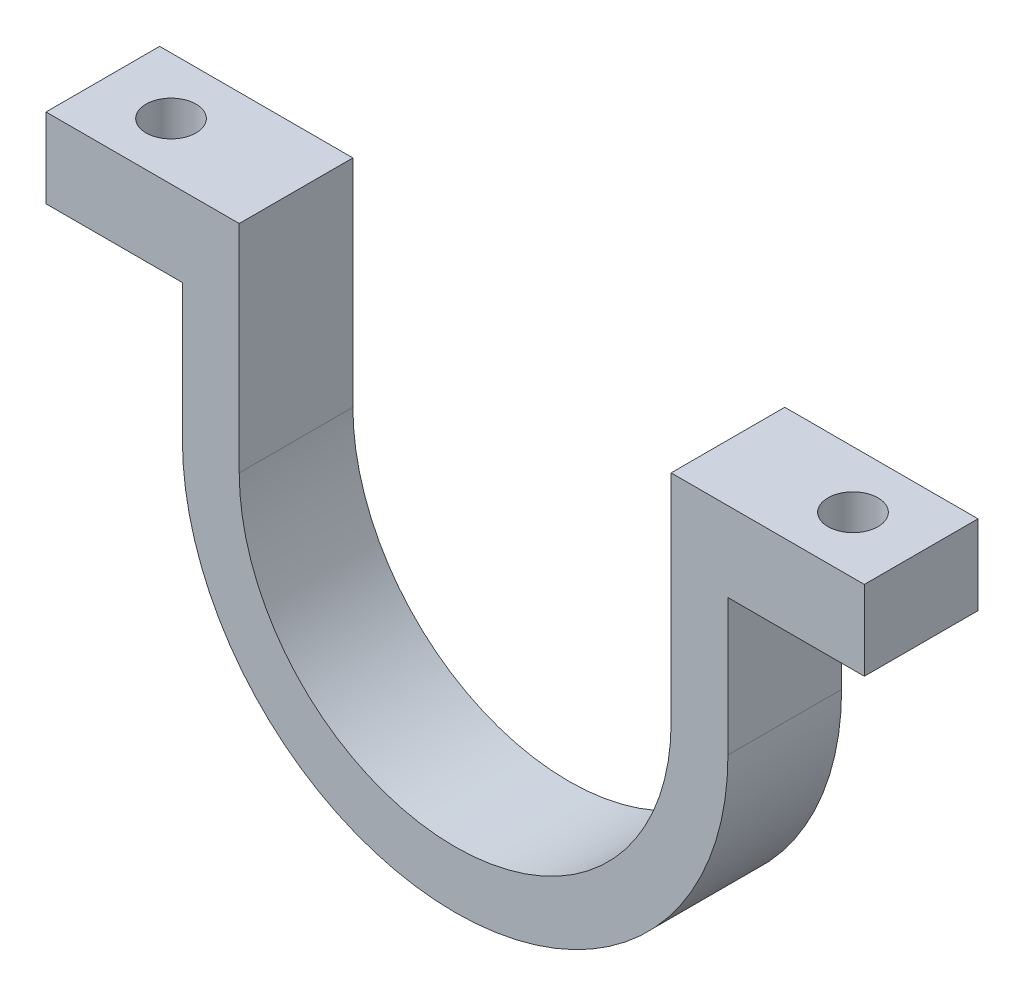
from build123d import *

# Parameters (mm, degrees)
RESSALTO_EXTRUS_O1_DEPTH = 10
ESBO_O2_R                = 2.2
CORTE_EXTRUS_O1_DEPTH    = 10


with BuildPart() as part:
    # Esboço1 → Ressalto-extrusão1 (new body)
    with BuildSketch(Plane.XY):
        with BuildLine():
            Line((-36, 19), (-19, 19))
            Line((-19, 19), (-19, 0))
            ThreePointArc((-19, 0), (0, -19), (19, 0))
            Line((19, 0), (19, 19))
            Line((19, 19), (36, 19))
            Line((36, 19), (36, 12))
            Line((36, 12), (24, 12))
            Line((24, 12), (24, 0))
            ThreePointArc((24, 0), (0, -24), (-24, 0))
            Line((-24, 0), (-24, 12))
            Line((-24, 12), (-36, 12))
            Line((-36, 12), (-36, 19))
        make_face()
    extrude(amount=RESSALTO_EXTRUS_O1_DEPTH)

    # Esboço2 → Corte-extrusão1 (cut)
    with BuildSketch(Plane(origin=(0, 19, 0), x_dir=(1, 0, 0), z_dir=(0, 1, 0))):
        with Locations((-30, -5)):
            Circle(ESBO_O2_R)
        with Locations((30, -5)):
            Circle(ESBO_O2_R)
    extrude(amount=-CORTE_EXTRUS_O1_DEPTH, mode=Mode.SUBTRACT)


solid = part.part
